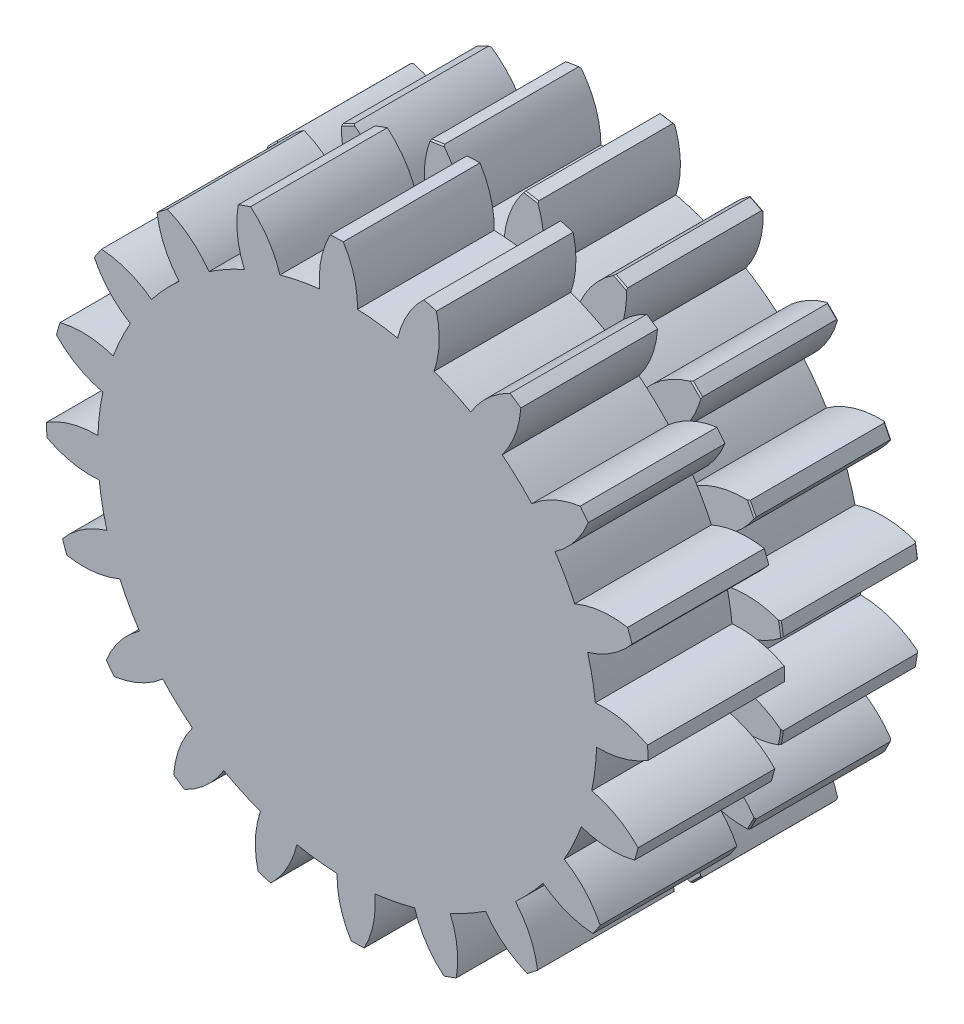
from build123d import *

# Parameters (mm, degrees)
SKETCH2_R                = 22
BOSS_EXTRUDE1_DEPTH      = 5
CUT_EXTRUDE1_DEPTH       = 10
FILLET1_R                = 0.6
CHAMFER1_SIZE            = 0.1
CIRPATTERN1_COUNT        = 20
FILLET1_OF_CIRPATTERN1_R = 0.6
CUT_EXTRUDE3_DEPTH       = 11.0000001
CIRPATTERN2_COUNT        = 20
SKETCH8_R                = 22
BOSS_EXTRUDE2_DEPTH      = 10
CUT_EXTRUDE4_DEPTH       = 10
CIRPATTERN3_COUNT        = 20
CUT_EXTRUDE5_DEPTH       = 10
CIRPATTERN4_COUNT        = 20


with BuildPart() as part:
    # Sketch2 → Boss-Extrude1 (new body, symmetric)
    with BuildSketch(Plane.XY):
        Circle(SKETCH2_R)
    extrude(amount=BOSS_EXTRUDE1_DEPTH, both=True)

    # Sketch3 → Cut-Extrude1 (cut)
    with BuildSketch(Plane.XY.offset(5)):
        with BuildLine():
            ThreePointArc((1.155064539, 17.962901378), (0, 18), (-1.155064539, 17.962901378))
            ThreePointArc((-1.155064539, 17.962901378), (-1.596564099, 20.012299891), (-2.616561789, 21.843845916))
            ThreePointArc((-2.616561789, 21.843845916), (0, 22), (2.616561789, 21.843845916))
            ThreePointArc((2.616561789, 21.843845916), (1.596564099, 20.012299891), (1.155064539, 17.962901378))
        make_face()
    cut_extrude1 = extrude(amount=-CUT_EXTRUDE1_DEPTH, mode=Mode.SUBTRACT)

    # Fillet1
    fillet1_edges = [part.edges().sort_by_distance(p)[0] for p in [
        (1.155064539, 17.962901378, 0),
        (-1.155064539, 17.962901378, 0),
    ]]
    fillet(fillet1_edges, radius=FILLET1_R)

    # Chamfer1
    chamfer1_edges = [part.edges().sort_by_distance(p)[0] for p in [
        (0, -22, -5),
        (0, -22, 5),
    ]]
    chamfer(chamfer1_edges, length=CHAMFER1_SIZE)

    # CirPattern1: Cut-Extrude1 ×20 about axis
    cirpattern1_axis = Axis((0, 0, 0), (0, 0, 1))
    for i in range(1, CIRPATTERN1_COUNT):
        add(cut_extrude1.rotate(cirpattern1_axis, i * 360 / CIRPATTERN1_COUNT), mode=Mode.SUBTRACT)

    # Fillet1 of CirPattern1
    fillet1_of_cirpattern1_edges = [part.edges().sort_by_distance(p)[0] for p in [
        (-4.452310137, 17.440668979, 0),
        (-6.649373451, 16.726799835, 0),
        (-9.623861676, 15.211222385, 0),
        (-11.49279536, 13.853362581, 0),
        (-13.853362581, 11.49279536, 0),
        (-15.211222385, 9.623861676, 0),
        (-16.726799835, 6.649373451, 0),
        (-17.440668979, 4.452310137, 0),
        (-17.962901378, 1.155064539, 0),
        (-17.962901378, -1.155064539, 0),
        (-17.440668979, -4.452310137, 0),
        (-16.726799835, -6.649373451, 0),
        (-15.211222385, -9.623861676, 0),
        (-13.853362581, -11.49279536, 0),
        (-11.49279536, -13.853362581, 0),
        (-9.623861676, -15.211222385, 0),
        (-6.649373451, -16.726799835, 0),
        (-4.452310137, -17.440668979, 0),
        (-1.155064539, -17.962901378, 0),
        (1.155064539, -17.962901378, 0),
        (4.452310137, -17.440668979, 0),
        (6.649373451, -16.726799835, 0),
        (9.623861676, -15.211222385, 0),
        (11.49279536, -13.853362581, 0),
        (13.853362581, -11.49279536, 0),
        (15.211222385, -9.623861676, 0),
        (16.726799835, -6.649373451, 0),
        (17.440668979, -4.452310137, 0),
        (17.962901378, -1.155064539, 0),
        (17.962901378, 1.155064539, 0),
        (17.440668979, 4.452310137, 0),
        (16.726799835, 6.649373451, 0),
        (15.211222385, 9.623861676, 0),
        (13.853362581, 11.49279536, 0),
        (11.49279536, 13.853362581, 0),
        (9.623861676, 15.211222385, 0),
        (6.649373451, 16.726799835, 0),
        (4.452310137, 17.440668979, 0),
    ]]
    fillet(fillet1_of_cirpattern1_edges, radius=FILLET1_OF_CIRPATTERN1_R)

    # Sketch6 → Cut-Extrude3 (cut, through all)
    with BuildSketch(Plane.XY.offset(5)):
        with BuildLine():
            Line((-2.968996641, 21.798739848), (-2.398118172, 24.056968699))
            Line((-2.398118172, 24.056968699), (2.778480736, 23.660222067))
            Line((2.778480736, 23.660222067), (2.968996641, 21.798739848))
            ThreePointArc((2.968996641, 21.798739848), (1.844757088, 19.805225799), (1.444976463, 17.55174221))
            ThreePointArc((1.444976463, 17.55174221), (0, 17.611121815), (-1.444976463, 17.55174221))
            ThreePointArc((-1.444976463, 17.55174221), (-1.844757088, 19.805225799), (-2.968996641, 21.798739848))
        make_face()
    cut_extrude3 = extrude(amount=-CUT_EXTRUDE3_DEPTH, mode=Mode.SUBTRACT)

    # CirPattern2: Cut-Extrude3 ×20 about axis
    cirpattern2_axis = Axis((0, 0, 0), (0, 0, 1))
    for i in range(1, CIRPATTERN2_COUNT):
        add(cut_extrude3.rotate(cirpattern2_axis, i * 360 / CIRPATTERN2_COUNT), mode=Mode.SUBTRACT)

    # Sketch8 → Boss-Extrude2 (add)
    with BuildSketch(Plane.XY.offset(5)):
        Circle(SKETCH8_R)
    extrude(amount=BOSS_EXTRUDE2_DEPTH)

    # Sketch9 → Cut-Extrude4 (cut)
    with BuildSketch(Plane.XY.offset(15)):
        with BuildLine():
            ThreePointArc((0.065036825, 21.999903868), (0.822762702, 20.182452368), (1.052926094, 18.226869777))
            ThreePointArc((1.052926094, 18.226869777), (2.22499993, 18.121170231), (3.387829199, 17.940179724))
            ThreePointArc((3.387829199, 17.940179724), (4.084254002, 19.781991591), (5.259153494, 21.362146534))
            ThreePointArc((5.259153494, 21.362146534), (2.681125555, 21.836015336), (0.065036825, 21.999903868))
        make_face()
    cut_extrude4 = extrude(amount=-CUT_EXTRUDE4_DEPTH, mode=Mode.SUBTRACT)

    # CirPattern3: Cut-Extrude4 ×20 about axis
    cirpattern3_axis = Axis((0, 0, 0), (0, 0, 1))
    for i in range(1, CIRPATTERN3_COUNT):
        add(cut_extrude4.rotate(cirpattern3_axis, i * 360 / CIRPATTERN3_COUNT), mode=Mode.SUBTRACT)

    # Sketch10 → Cut-Extrude5 (cut)
    with BuildSketch(Plane.XY.offset(15)):
        with BuildLine():
            ThreePointArc((0.748759819, 18.241896666), (0.503879719, 20.195959405), (-0.290268081, 21.998085018))
            ThreePointArc((-0.290268081, 21.998085018), (2.681125555, 21.836015336), (5.603464305, 21.274425674))
            ThreePointArc((5.603464305, 21.274425674), (4.396932445, 19.717952635), (3.686595768, 17.881175769))
            ThreePointArc((3.686595768, 17.881175769), (2.22499993, 18.121170231), (0.748759819, 18.241896666))
        make_face()
    cut_extrude5 = extrude(amount=-CUT_EXTRUDE5_DEPTH, mode=Mode.SUBTRACT)

    # CirPattern4: Cut-Extrude5 ×20 about axis
    cirpattern4_axis = Axis((0, 0, 0), (0, 0, 1))
    for i in range(1, CIRPATTERN4_COUNT):
        add(cut_extrude5.rotate(cirpattern4_axis, i * 360 / CIRPATTERN4_COUNT), mode=Mode.SUBTRACT)


solid = part.part
